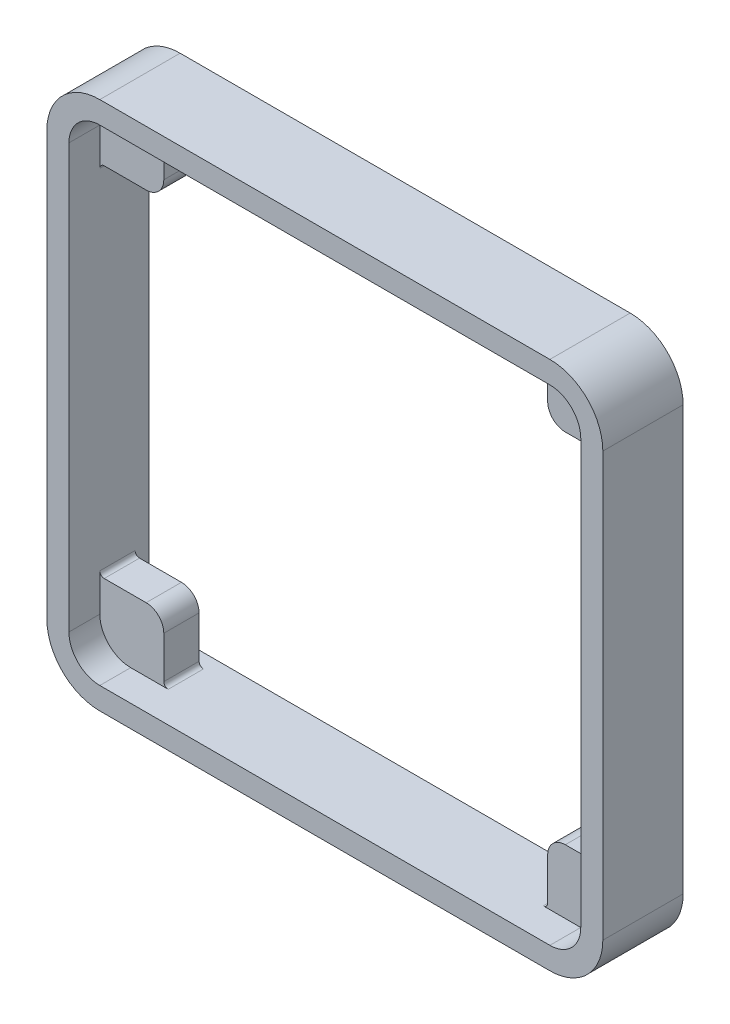
from build123d import *

# Parameters (mm, degrees)
BOSS_EXTRU_1_DEPTH = 7.5
ESQUISSE2_W        = 7.25
ESQUISSE2_H        = 7.25
BOSS_EXTRU_2_DEPTH = 4
CONG_1_R           = 2
CONG_2_R           = 0.5
BOSS_EXTRU_3_START = -1.6
BOSS_EXTRU_3_DEPTH = 1.6


with BuildPart() as part:
    # Esquisse1 → Boss.-Extru.1 (new body)
    with BuildSketch(Plane.XY.offset(-1424.691834437)):
        with BuildLine():
            Line((670.002412047, 1197.108127391), (670.002412047, 1149.108126022))
            ThreePointArc((670.002412047, 1149.108126022), (671.759771358, 1144.86548622), (676.002410874, 1143.108126218))
            Line((676.002410874, 1143.108126218), (727.002412047, 1143.108126218))
            ThreePointArc((727.002412047, 1143.108126218), (731.245051976, 1144.865485459), (733.002412047, 1149.108125045))
            Line((733.002412047, 1149.108125045), (733.002412047, 1197.108126218))
            ThreePointArc((733.002412047, 1197.108126218), (731.245052806, 1201.350766146), (727.00241322, 1203.108126218))
            Line((727.00241322, 1203.108126218), (676.00241121, 1203.108126218))
            ThreePointArc((676.00241121, 1203.108126218), (671.759771822, 1201.35076668), (670.002412047, 1197.108127391))
        make_face()
        with BuildLine():
            Line((676.002411852, 1145.608126218), (727.002412047, 1145.608126218))
            ThreePointArc((727.002412047, 1145.608126218), (729.477285369, 1146.633252758), (730.502412047, 1149.108126022))
            Line((730.502412047, 1149.108126022), (730.502412047, 1197.108126218))
            ThreePointArc((730.502412047, 1197.108126218), (729.477285507, 1199.582999539), (727.002412243, 1200.608126218))
            Line((727.002412243, 1200.608126218), (676.002412047, 1200.608126218))
            ThreePointArc((676.002412047, 1200.608126218), (673.527538726, 1199.582999677), (672.502412047, 1197.108126413))
            Line((672.502412047, 1197.108126413), (672.502412047, 1149.108126022))
            ThreePointArc((672.502412047, 1149.108126022), (673.527538657, 1146.633252827), (676.002411852, 1145.608126218))
        make_face(mode=Mode.SUBTRACT)
    extrude(amount=BOSS_EXTRU_1_DEPTH)

    # Esquisse2 → Boss.-Extru.2 (add)
    with BuildSketch(Plane(origin=(0, 0, -1424.691834437), x_dir=(1, 0, 0), z_dir=(0, 0, -1))):
        with Locations((676.127412047, -1149.233126218)):
            Rectangle(ESQUISSE2_W, ESQUISSE2_H)
        with Locations((726.877412243, -1149.233126218)):
            Rectangle(ESQUISSE2_W, ESQUISSE2_H)
        with Locations((726.877412243, -1196.983126022)):
            Rectangle(ESQUISSE2_W, ESQUISSE2_H)
        with Locations((676.127412047, -1196.983126022)):
            Rectangle(ESQUISSE2_W, ESQUISSE2_H)
    extrude(amount=-BOSS_EXTRU_2_DEPTH)

    # Congé1
    cong_1_edges = [part.edges().sort_by_distance(p)[0] for p in [
        (723.252412243, 1152.858126218, -1422.691834437),
        (723.252412243, 1193.358126022, -1422.691834437),
        (679.752412047, 1193.358126022, -1422.691834437),
        (679.752412047, 1152.858126218, -1422.691834437),
    ]]
    fillet(cong_1_edges, radius=CONG_1_R)

    # Congé2
    cong_2_edges = [part.edges().sort_by_distance(p)[0] for p in [
        (723.252412243, 1145.608126218, -1422.691834437),
        (730.502412243, 1152.858126218, -1422.691834437),
        (723.252412243, 1200.608126022, -1422.691834437),
        (730.502412243, 1193.358126022, -1422.691834437),
        (679.752412047, 1145.608126218, -1422.691834437),
        (672.502412047, 1152.858126218, -1422.691834437),
        (672.502412047, 1193.358126022, -1422.691834437),
        (679.752412047, 1200.608126022, -1422.691834437),
    ]]
    fillet(cong_2_edges, radius=CONG_2_R)

    # Esquisse1_2 → Boss.-Extru.3 (add)
    with BuildSketch(Plane.XY.offset(-1424.691834437).offset(BOSS_EXTRU_3_START)):
        with BuildLine():
            Line((670.002412047, 1197.108127391), (670.002412047, 1149.108126022))
            ThreePointArc((670.002412047, 1149.108126022), (671.759771358, 1144.86548622), (676.002410874, 1143.108126218))
            Line((676.002410874, 1143.108126218), (727.002412047, 1143.108126218))
            ThreePointArc((727.002412047, 1143.108126218), (731.245051976, 1144.865485459), (733.002412047, 1149.108125045))
            Line((733.002412047, 1149.108125045), (733.002412047, 1197.108126218))
            ThreePointArc((733.002412047, 1197.108126218), (731.245052806, 1201.350766146), (727.00241322, 1203.108126218))
            Line((727.00241322, 1203.108126218), (676.00241121, 1203.108126218))
            ThreePointArc((676.00241121, 1203.108126218), (671.759771822, 1201.35076668), (670.002412047, 1197.108127391))
        make_face()
        with BuildLine():
            Line((676.002411852, 1145.608126218), (727.002412047, 1145.608126218))
            ThreePointArc((727.002412047, 1145.608126218), (729.477285369, 1146.633252758), (730.502412047, 1149.108126022))
            Line((730.502412047, 1149.108126022), (730.502412047, 1197.108126218))
            ThreePointArc((730.502412047, 1197.108126218), (729.477285507, 1199.582999539), (727.002412243, 1200.608126218))
            Line((727.002412243, 1200.608126218), (676.002412047, 1200.608126218))
            ThreePointArc((676.002412047, 1200.608126218), (673.527538726, 1199.582999677), (672.502412047, 1197.108126413))
            Line((672.502412047, 1197.108126413), (672.502412047, 1149.108126022))
            ThreePointArc((672.502412047, 1149.108126022), (673.527538657, 1146.633252827), (676.002411852, 1145.608126218))
        make_face(mode=Mode.SUBTRACT)
    extrude(amount=BOSS_EXTRU_3_DEPTH)


solid = part.part
